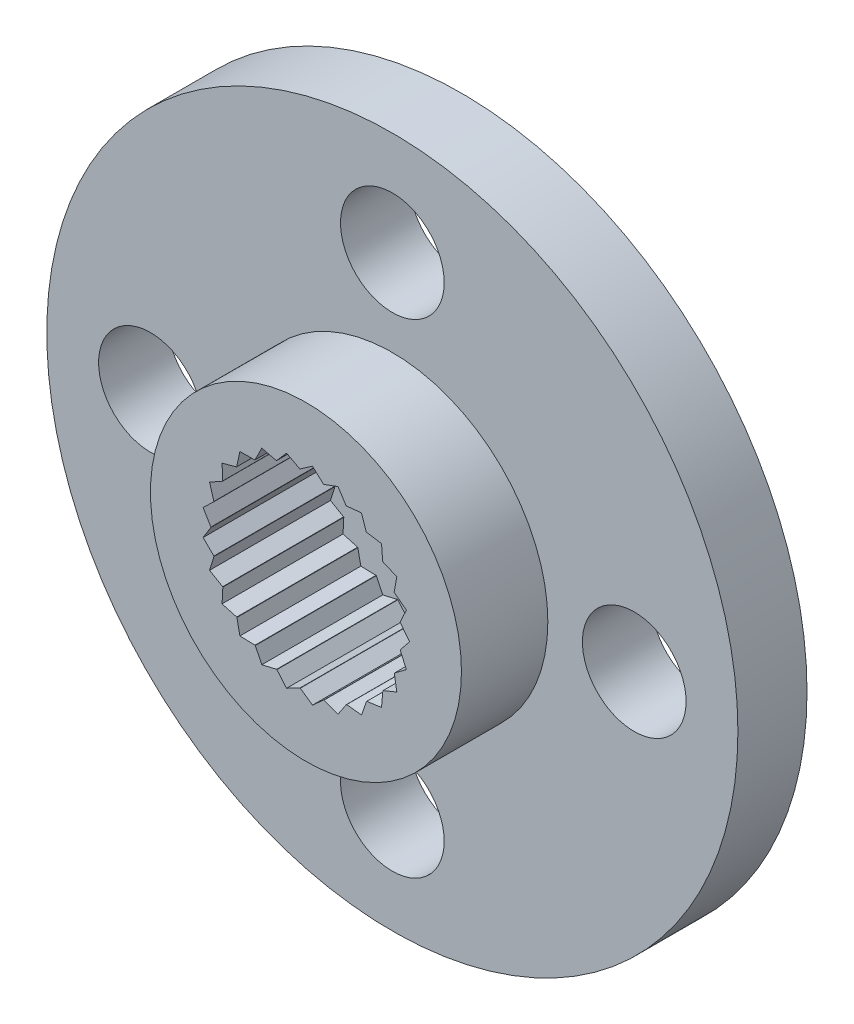
from build123d import *

# Parameters (mm, degrees)
SKETCH1_R           = 10
SKETCH1_R_2         = 1.5
SKETCH1_R_3         = 4.5
BOSS_EXTRUDE1_DEPTH = 2
SKETCH1_2_R         = 4.5
BOSS_EXTRUDE2_DEPTH = 4.5
SKETCH2_R           = 1.5
CUT_EXTRUDE1_DEPTH  = 4.5
SKETCH3_R           = 2.75
CUT_EXTRUDE2_DEPTH  = 3.5
CUT_EXTRUDE3_DEPTH  = 3.5
CIRPATTERN1_COUNT   = 25


with BuildPart() as part:
    # Sketch1 → Boss-Extrude1 (new body)
    with BuildSketch(Plane.XY):
        Circle(SKETCH1_R)
        with Locations((0, 7)):
            Circle(SKETCH1_R_2, mode=Mode.SUBTRACT)
        with Locations((7, 0)):
            Circle(SKETCH1_R_2, mode=Mode.SUBTRACT)
        with Locations((0, -7)):
            Circle(SKETCH1_R_2, mode=Mode.SUBTRACT)
        with Locations((-7, 0)):
            Circle(SKETCH1_R_2, mode=Mode.SUBTRACT)
        Circle(SKETCH1_R_3, mode=Mode.SUBTRACT)
    extrude(amount=BOSS_EXTRUDE1_DEPTH)

    # Sketch1_2 → Boss-Extrude2 (add)
    with BuildSketch(Plane.XY):
        Circle(SKETCH1_2_R)
    extrude(amount=BOSS_EXTRUDE2_DEPTH)

    # Sketch2 → Cut-Extrude1 (cut)
    with BuildSketch(Plane(origin=(0, 0, 0), x_dir=(-1, 0, 0), z_dir=(0, 0, -1))):
        Circle(SKETCH2_R)
    extrude(amount=-CUT_EXTRUDE1_DEPTH, mode=Mode.SUBTRACT)

    # Sketch3 → Cut-Extrude2 (cut)
    with BuildSketch(Plane.XY.offset(4.5)):
        Circle(SKETCH3_R)
    extrude(amount=-CUT_EXTRUDE2_DEPTH, mode=Mode.SUBTRACT)

    # Sketch4 → Cut-Extrude3 (cut)
    with BuildSketch(Plane.XY.offset(4.5)):
        with BuildLine():
            Line((-2.976344104, 0.375999701), (-2.75, 0))
            ThreePointArc((-2.75, 0), (-2.728912829, 0.339904061), (-2.665974712, 0.674595311))
            Line((-2.665974712, 0.674595311), (-2.976344104, 0.375999701))
        make_face()
    cut_extrude3 = extrude(amount=-CUT_EXTRUDE3_DEPTH, mode=Mode.SUBTRACT)

    # CirPattern1: Cut-Extrude3 ×25 about axis
    cirpattern1_axis = Axis((0, 0, 4.5), (0, 0, -1))
    for i in range(1, CIRPATTERN1_COUNT):
        add(cut_extrude3.rotate(cirpattern1_axis, i * 360 / CIRPATTERN1_COUNT), mode=Mode.SUBTRACT)


solid = part.part
